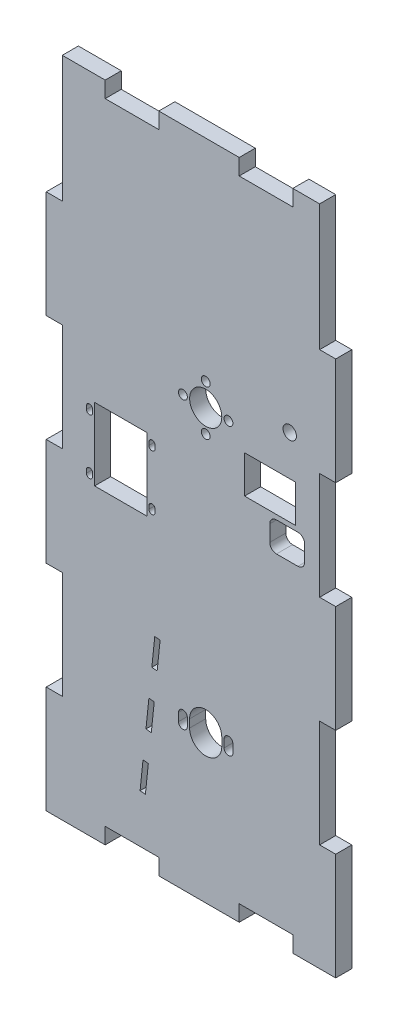
from build123d import *

# Parameters (mm, degrees)
ESQUISSE1_R        = 1.65
ESQUISSE1_R_2      = 6
ESQUISSE1_R_3      = 2.5
ESQUISSE1_W        = 19.5
ESQUISSE1_H        = 27
ESQUISSE1_W_2      = 19
ESQUISSE1_H_2      = 14
BOSS_EXTRU_1_DEPTH = 6


with BuildPart() as part:
    # Esquisse1 → Boss.-Extru.1 (new body)
    with BuildSketch(Plane.XY.offset(-2)):
        Polygon((2459.723805414, -65.693190997), (2443.723805414, -65.693190997), (2443.723805414, -59.693190997), (2423.723805414, -59.693190997), (2423.723805414, -65.693190997), (2393.723805414, -65.693190997), (2393.723805414, -59.693190997), (2373.723805414, -59.693190997), (2373.723805414, -65.693190997), (2351.723805414, -65.693190997), (2351.723805414, -25.693190997), (2357.723805414, -25.693190997), (2357.723805414, 14.306809003), (2351.723805414, 14.306809003), (2351.723805414, 54.306809003), (2357.723805414, 54.306809003), (2357.723805414, 94.306809003), (2351.723805414, 94.306809003), (2351.723805414, 134.306809003), (2357.723805414, 134.306809003), (2357.723805414, 181.409908735), (2373.723805414, 181.409908735), (2373.723805414, 175.409908735), (2393.723805414, 175.409908735), (2393.723805414, 181.409908735), (2423.723805414, 181.409908735), (2423.723805414, 175.409908735), (2443.723805414, 175.409908735), (2443.723805414, 181.409908735), (2453.723805414, 181.409908735), (2453.723805414, 134.306809003), (2459.723805414, 134.306809003), (2459.723805414, 94.306809003), (2453.723805414, 94.306809003), (2453.723805414, 54.306809003), (2459.723805414, 54.306809003), (2459.723805414, 14.306809003), (2453.723805414, 14.306809003), (2453.723805414, -25.693190997), (2459.723805414, -25.693190997), align=None)
        with Locations((2411.223763127, 102.806809003)):
            Circle(ESQUISSE1_R, mode=Mode.SUBTRACT)
        with Locations((2419.723805414, 94.306851291)):
            Circle(ESQUISSE1_R, mode=Mode.SUBTRACT)
        with Locations((2411.223805414, 94.306809003)):
            Circle(ESQUISSE1_R_2, mode=Mode.SUBTRACT)
        with Locations((2402.723805414, 94.306766716)):
            Circle(ESQUISSE1_R, mode=Mode.SUBTRACT)
        with Locations((2411.223847701, 85.806809003)):
            Circle(ESQUISSE1_R, mode=Mode.SUBTRACT)
        with Locations((2442.573805414, 102.010809003)):
            Circle(ESQUISSE1_R_3, mode=Mode.SUBTRACT)
        with Locations((2379.523805414, 61.806809003)):
            Rectangle(ESQUISSE1_W, ESQUISSE1_H, mode=Mode.SUBTRACT)
        with BuildLine():
            Line((2366.723805414, 71.506809003), (2366.723805414, 72.706809003))
            ThreePointArc((2366.723805414, 72.706809003), (2367.873805414, 73.856809003), (2369.023805414, 72.706809003))
            Line((2369.023805414, 72.706809003), (2369.023805414, 71.506809003))
            ThreePointArc((2369.023805414, 71.506809003), (2367.873805414, 70.356809003), (2366.723805414, 71.506809003))
        make_face(mode=Mode.SUBTRACT)
        with BuildLine():
            Line((2392.323805414, 72.706809003), (2392.323805414, 71.506809003))
            ThreePointArc((2392.323805414, 71.506809003), (2391.173805414, 70.356809003), (2390.023805414, 71.506809003))
            Line((2390.023805414, 71.506809003), (2390.023805414, 72.706809003))
            ThreePointArc((2390.023805414, 72.706809003), (2391.173805414, 73.856809003), (2392.323805414, 72.706809003))
        make_face(mode=Mode.SUBTRACT)
        with BuildLine():
            Line((2392.323805414, 52.106809003), (2392.323805414, 50.906809003))
            ThreePointArc((2392.323805414, 50.906809003), (2391.173805414, 49.756809003), (2390.023805414, 50.906809003))
            Line((2390.023805414, 50.906809003), (2390.023805414, 52.106809003))
            ThreePointArc((2390.023805414, 52.106809003), (2391.173805414, 53.256809003), (2392.323805414, 52.106809003))
        make_face(mode=Mode.SUBTRACT)
        with BuildLine():
            Line((2366.723805414, 52.106809003), (2366.723805414, 50.906809003))
            ThreePointArc((2366.723805414, 50.906809003), (2367.873805414, 49.756809003), (2369.023805414, 50.906809003))
            Line((2369.023805414, 50.906809003), (2369.023805414, 52.106809003))
            ThreePointArc((2369.023805414, 52.106809003), (2367.873805414, 53.256809003), (2366.723805414, 52.106809003))
        make_face(mode=Mode.SUBTRACT)
        with BuildLine():
            Line((2418.073805414, -9.193190997), (2418.073805414, -12.193190997))
            ThreePointArc((2418.073805414, -12.193190997), (2419.723805414, -13.843190997), (2421.373805414, -12.193190997))
            Line((2421.373805414, -12.193190997), (2421.373805414, -9.193190997))
            ThreePointArc((2421.373805414, -9.193190997), (2419.723805414, -7.543190997), (2418.073805414, -9.193190997))
        make_face(mode=Mode.SUBTRACT)
        with BuildLine():
            Line((2401.073805414, -9.193190997), (2401.073805414, -12.193190997))
            ThreePointArc((2401.073805414, -12.193190997), (2402.723805414, -13.843190997), (2404.373805414, -12.193190997))
            Line((2404.373805414, -12.193190997), (2404.373805414, -9.193190997))
            ThreePointArc((2404.373805414, -9.193190997), (2402.723805414, -7.543190997), (2401.073805414, -9.193190997))
        make_face(mode=Mode.SUBTRACT)
        with BuildLine():
            Line((2405.223805414, -9.193190997), (2405.223805414, -12.193190997))
            ThreePointArc((2405.223805414, -12.193190997), (2411.223805414, -18.193190997), (2417.223805414, -12.193190997))
            Line((2417.223805414, -12.193190997), (2417.223805414, -9.193190997))
            ThreePointArc((2417.223805414, -9.193190997), (2411.223805414, -3.193190997), (2405.223805414, -9.193190997))
        make_face(mode=Mode.SUBTRACT)
        with Locations((2435.223805414, 80.010809003)):
            Rectangle(ESQUISSE1_W_2, ESQUISSE1_H_2, mode=Mode.SUBTRACT)
        with BuildLine():
            Line((2448.123805414, 68.756809003), (2448.123805414, 62.756809003))
            ThreePointArc((2448.123805414, 62.756809003), (2447.391572367, 60.98904205), (2445.623805414, 60.256809003))
            Line((2445.623805414, 60.256809003), (2437.623805414, 60.256809003))
            ThreePointArc((2437.623805414, 60.256809003), (2435.856038461, 60.98904205), (2435.123805414, 62.756809003))
            Line((2435.123805414, 62.756809003), (2435.123805414, 68.756809003))
            ThreePointArc((2435.123805414, 68.756809003), (2435.856038461, 70.524575956), (2437.623805414, 71.256809003))
            Line((2437.623805414, 71.256809003), (2445.623805414, 71.256809003))
            ThreePointArc((2445.623805414, 71.256809003), (2447.391572367, 70.524575956), (2448.123805414, 68.756809003))
        make_face(mode=Mode.SUBTRACT)
        Polygon((2386.739083665, -41.66500263), (2387.836028015, -31.150640303), (2389.825231698, -31.358170315), (2388.728287348, -41.872532642), align=None, mode=Mode.SUBTRACT)
        Polygon((2388.932972364, -20.636277977), (2390.029916714, -10.12191565), (2392.019120398, -10.329445662), (2390.922176048, -20.843807989), align=None, mode=Mode.SUBTRACT)
        Polygon((2391.126861064, 0.392446677), (2392.223805414, 10.906809003), (2394.213009097, 10.699278991), (2393.116064748, 0.184916664), align=None, mode=Mode.SUBTRACT)
    extrude(amount=BOSS_EXTRU_1_DEPTH)


solid = part.part
